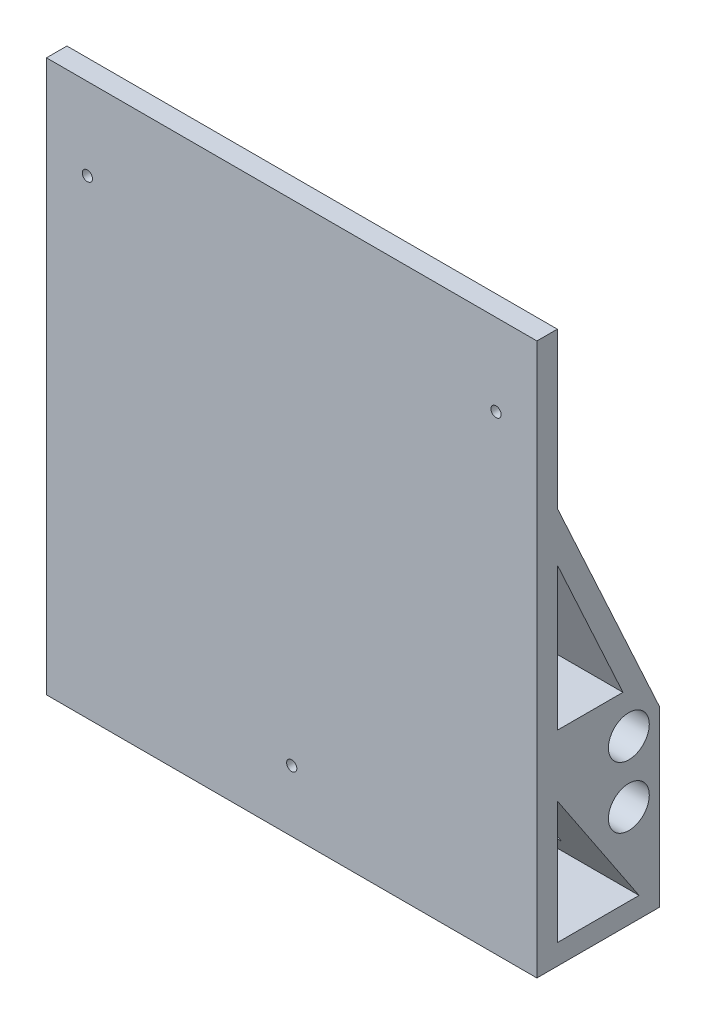
from build123d import *

# Parameters (mm, degrees)
SKETCH1_R                = 5
BOSS_EXTRUDE1_DEPTH      = 120
SKETCH2_R                = 3.75
BOSS_EXTRUDE2_DEPTH      = 20
SKETCH3_R                = 3.75
BOSS_EXTRUDE3_DEPTH      = 20
BOSS_EXTRUDE3_DEPTH_BACK = 15
SKETCH4_R                = 1.25
CUT_EXTRUDE1_DEPTH       = 50
SKETCH5_W                = 90
SKETCH5_H                = 25
CUT_EXTRUDE5_DEPTH       = 25
SKETCH6_R                = 5
BOSS_EXTRUDE4_DEPTH      = 5
SKETCH7_R                = 5
BOSS_EXTRUDE5_DEPTH      = 5
SKETCH8_R                = 5
BOSS_EXTRUDE6_DEPTH      = 95
BOSS_EXTRUDE6_DEPTH_BACK = 5
SKETCH9_W                = 90
SKETCH9_H                = 25
BOSS_EXTRUDE7_DEPTH      = 2.5
SKETCH10_R               = 1.25
CUT_EXTRUDE6_DEPTH       = 22.5
CUT_EXTRUDE7_DEPTH       = 120


with BuildPart() as part:
    # Sketch1 → Boss-Extrude1 (new body)
    with BuildSketch(Plane(origin=(0, 0, 0), x_dir=(0, 0, -1), z_dir=(1, 0, 0))):
        Polygon((0, 0), (0, 135), (5, 135), (5, 97), (30, 42.5), (30, 0), align=None)
        with Locations((22.5, 40)):
            Circle(SKETCH1_R, mode=Mode.SUBTRACT)
        with Locations((22.5, 25)):
            Circle(SKETCH1_R, mode=Mode.SUBTRACT)
        Polygon((25, 5), (5, 35), (5, 5), align=None, mode=Mode.SUBTRACT)
    extrude(amount=-BOSS_EXTRUDE1_DEPTH)

    # Sketch2 → Boss-Extrude2 (add)
    with BuildSketch(Plane(origin=(0, 0, -30), x_dir=(-1, 0, 0), z_dir=(0, 0, -1))):
        with Locations((60, 3.75)):
            Circle(SKETCH2_R)
    extrude(amount=BOSS_EXTRUDE2_DEPTH)

    # Sketch3 → Boss-Extrude3 (add, two sides)
    with BuildSketch(Plane(origin=(0, 0, -30), x_dir=(-1, 0, 0), z_dir=(0, 0, -1))) as boss_extrude3_sk:
        with Locations((60, 52.25)):
            Circle(SKETCH3_R)
    extrude(amount=BOSS_EXTRUDE3_DEPTH)
    extrude(boss_extrude3_sk.sketch, amount=-BOSS_EXTRUDE3_DEPTH_BACK)

    # Sketch4 → Cut-Extrude1 (cut)
    with BuildSketch(Plane.XY):
        with Locations((-60, 15)):
            Circle(SKETCH4_R)
    extrude(amount=-CUT_EXTRUDE1_DEPTH, mode=Mode.SUBTRACT)

    # Sketch5 → Cut-Extrude5 (cut)
    with BuildSketch(Plane(origin=(0, 0, -30), x_dir=(-1, 0, 0), z_dir=(0, 0, -1))):
        with Locations((60, 23.5)):
            Rectangle(SKETCH5_W, SKETCH5_H)
    extrude(amount=-CUT_EXTRUDE5_DEPTH, mode=Mode.SUBTRACT)

    # Sketch6 → Boss-Extrude4 (add)
    with BuildSketch(Plane.ZY.offset(15)):
        with Locations((-22.5, 25)):
            Circle(SKETCH6_R)
    extrude(amount=-BOSS_EXTRUDE4_DEPTH)

    # Sketch7 → Boss-Extrude5 (add)
    with BuildSketch(Plane(origin=(-105, 0, 0), x_dir=(0, 0, -1), z_dir=(1, 0, 0))):
        with Locations((22.5, 25)):
            Circle(SKETCH7_R)
    extrude(amount=-BOSS_EXTRUDE5_DEPTH)

    # Sketch8 → Boss-Extrude6 (add, two sides)
    with BuildSketch(Plane.ZY.offset(15)) as boss_extrude6_sk:
        with Locations((-22.5, 40)):
            Circle(SKETCH8_R)
    extrude(amount=BOSS_EXTRUDE6_DEPTH)
    extrude(boss_extrude6_sk.sketch, amount=-BOSS_EXTRUDE6_DEPTH_BACK)

    # Sketch9 → Boss-Extrude7 (add)
    with BuildSketch(Plane.XZ.offset(-36)):
        with Locations((-60, -17.5)):
            Rectangle(SKETCH9_W, SKETCH9_H)
    extrude(amount=BOSS_EXTRUDE7_DEPTH)

    # Sketch10 → Cut-Extrude6 (cut)
    with BuildSketch(Plane.XY):
        with Locations((-110, 115)):
            Circle(SKETCH10_R)
        with Locations((-10, 115)):
            Circle(SKETCH10_R)
    extrude(amount=-CUT_EXTRUDE6_DEPTH, mode=Mode.SUBTRACT)

    # Sketch11 → Cut-Extrude7 (cut)
    with BuildSketch(Plane(origin=(0, 0, 0), x_dir=(0, 0, -1), z_dir=(1, 0, 0))):
        Polygon((5, 85.00791928), (5, 50.00791928), (21.055045872, 50.00791928), align=None)
    extrude(amount=-CUT_EXTRUDE7_DEPTH, mode=Mode.SUBTRACT)


solid = part.part
